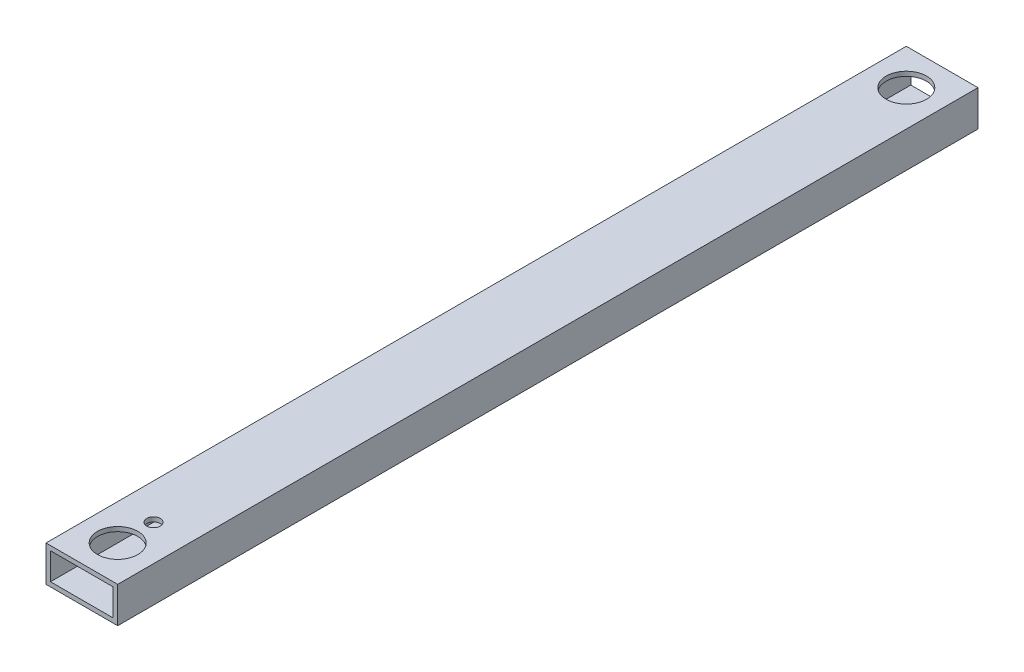
from build123d import *

# Parameters (mm, degrees)
SKETCH1_W           = 50.8
SKETCH1_H           = 25.4
BOSS_EXTRUDE1_DEPTH = 609.6
SKETCH2_W           = 44.45
SKETCH2_H           = 19.05
CUT_EXTRUDE1_DEPTH  = 635
SKETCH6_R           = 14.2875
CUT_EXTRUDE5_DEPTH  = 3.175
SKETCH7_R           = 14.2875
CUT_EXTRUDE6_DEPTH  = 3.175
SKETCH8_R           = 4.7625
CUT_EXTRUDE7_DEPTH  = 25.4


with BuildPart() as part:
    # Sketch1 → Boss-Extrude1 (new body)
    with BuildSketch(Plane.XY):
        with Locations((25.4, 12.7)):
            Rectangle(SKETCH1_W, SKETCH1_H)
    extrude(amount=BOSS_EXTRUDE1_DEPTH)

    # Sketch2 → Cut-Extrude1 (cut)
    with BuildSketch(Plane(origin=(0, 0, 0), x_dir=(-1, 0, 0), z_dir=(0, 0, -1))):
        with Locations((-25.4, 12.7)):
            Rectangle(SKETCH2_W, SKETCH2_H)
    extrude(amount=-CUT_EXTRUDE1_DEPTH, mode=Mode.SUBTRACT)

    # Sketch6 → Cut-Extrude5 (cut)
    with BuildSketch(Plane(origin=(0, 25.4, 0), x_dir=(1, 0, 0), z_dir=(0, 1, 0))):
        with Locations((25.4, -25.4)):
            Circle(SKETCH6_R)
    extrude(amount=-CUT_EXTRUDE5_DEPTH, mode=Mode.SUBTRACT)

    # Sketch7 → Cut-Extrude6 (cut)
    with BuildSketch(Plane(origin=(0, 25.4, 0), x_dir=(1, 0, 0), z_dir=(0, 1, 0))):
        with Locations((25.4, -584.2)):
            Circle(SKETCH7_R)
    extrude(amount=-CUT_EXTRUDE6_DEPTH, mode=Mode.SUBTRACT)

    # Sketch8 → Cut-Extrude7 (cut)
    with BuildSketch(Plane(origin=(0, 0, 0), x_dir=(-1, 0, 0), z_dir=(0, -1, 0))):
        with Locations((-25.4, -558.8)):
            Circle(SKETCH8_R)
    extrude(amount=-CUT_EXTRUDE7_DEPTH, mode=Mode.SUBTRACT)


solid = part.part
